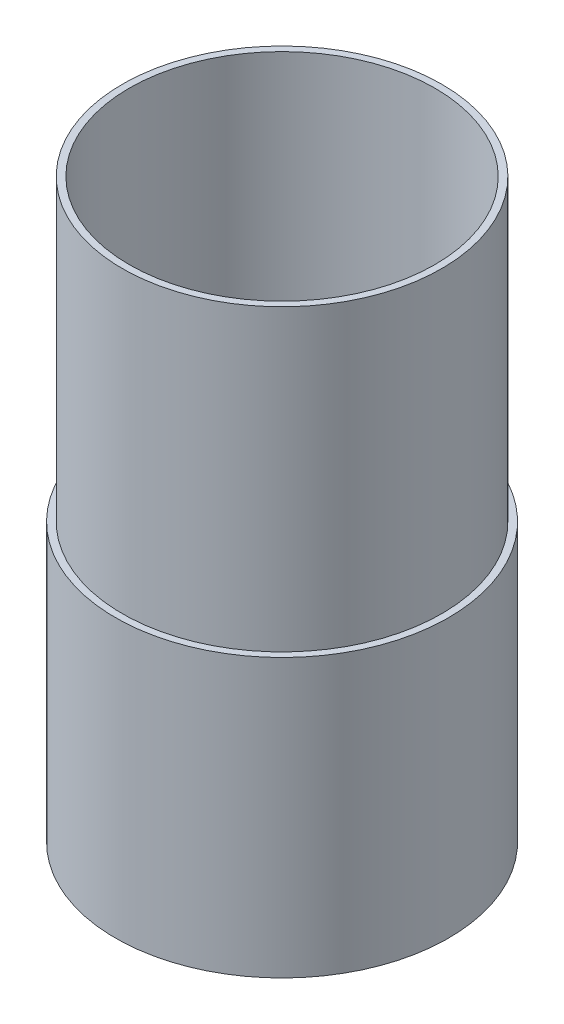
from build123d import *


with BuildPart() as part:
    # Sketch2 → Revolve1 (revolve)
    with BuildSketch(Plane.XY):
        Polygon((-4.064, 0), (-4.064, 82.55), (-2.032, 82.55), (-2.032, 171.45), (0, 171.45), (0, 0), align=None)
    revolve(axis=Axis((45.466, 0, 0), (0, 1, 0)))


solid = part.part
